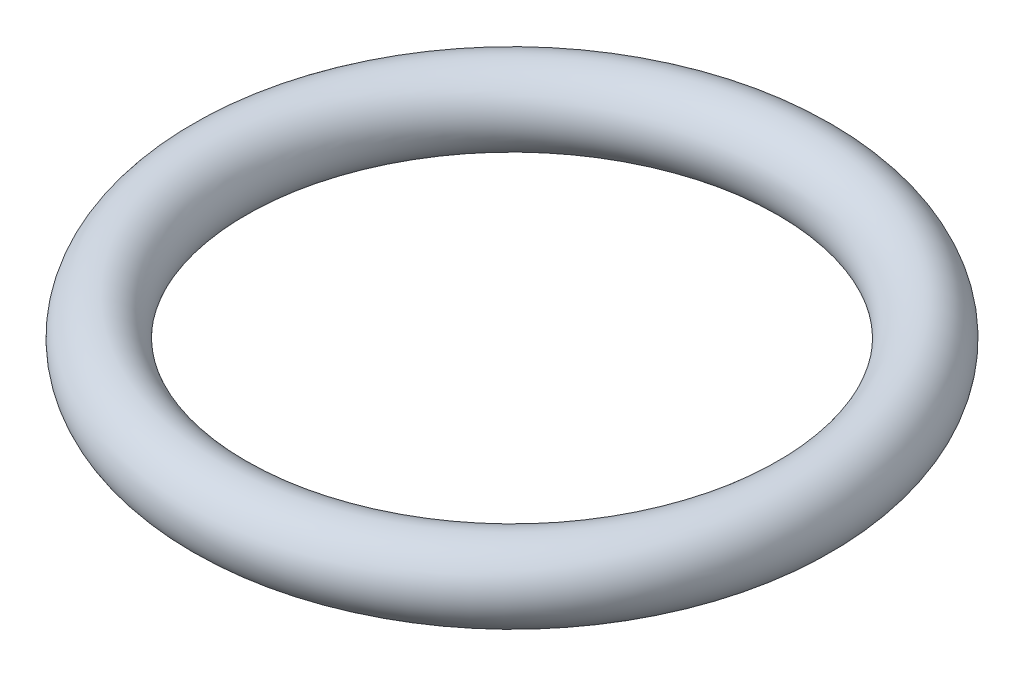
from build123d import *

# Parameters (mm, degrees)
ESQUISSE2_R = 1.5


with BuildPart() as part:
    # Balayage1: sweep along a path in Esquisse1
    with BuildLine(Plane(origin=(0, 0, 0), x_dir=(1, 0, 0), z_dir=(0, 1, 0))) as balayage1_path:
        CenterArc((0, 0), 11.75, 0, 360)
    # Esquisse2 → Balayage1 (sweep)
    with BuildSketch(Plane(origin=(0, 0, 0), x_dir=(0, 0, -1), z_dir=(1, 0, 0))):
        with Locations((11.75, 0)):
            Circle(ESQUISSE2_R)
    sweep(path=balayage1_path.line)


solid = part.part
